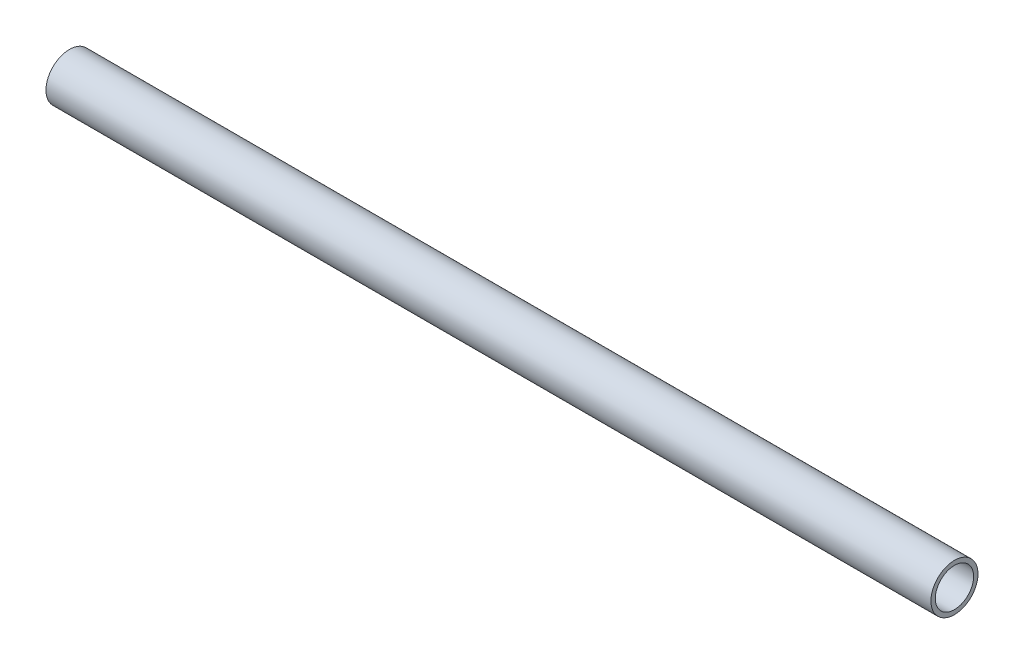
from build123d import *

# Parameters (mm, degrees)
SKETCH11_R               = 7.9375
SKETCH11_R_2             = 6.4643
STRUCTURAL_MEMBER1_DEPTH = 298.45


with BuildPart() as part:
    # Sketch11 → Structural Member1 (new body)
    with BuildSketch(Plane.YZ):
        Circle(SKETCH11_R)
        Circle(SKETCH11_R_2, mode=Mode.SUBTRACT)
    extrude(amount=STRUCTURAL_MEMBER1_DEPTH)


solid = part.part
